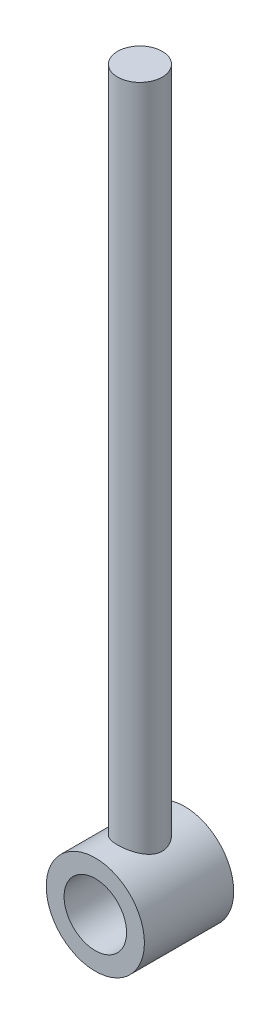
from build123d import *

# Parameters (mm, degrees)
SKETCH1_R           = 5.5
SKETCH1_R_2         = 3.5
BOSS_EXTRUDE1_DEPTH = 10
SKETCH2_R           = 2.5
BOSS_EXTRUDE2_DEPTH = 80
SKETCH3_R           = 3.5
CUT_EXTRUDE1_DEPTH  = 11.0000001


with BuildPart() as part:
    # Sketch1 → Boss-Extrude1 (new body)
    with BuildSketch(Plane.XY):
        Circle(SKETCH1_R)
        Circle(SKETCH1_R_2, mode=Mode.SUBTRACT)
    extrude(amount=BOSS_EXTRUDE1_DEPTH)

    # Sketch2 → Boss-Extrude2 (add)
    with BuildSketch(Plane(origin=(0, 0, 0), x_dir=(1, 0, 0), z_dir=(0, 1, 0))):
        with Locations((0, -5)):
            Circle(SKETCH2_R)
    extrude(amount=BOSS_EXTRUDE2_DEPTH)

    # Sketch3 → Cut-Extrude1 (cut, through all)
    with BuildSketch(Plane.XY.offset(10)):
        Circle(SKETCH3_R)
    extrude(amount=-CUT_EXTRUDE1_DEPTH, mode=Mode.SUBTRACT)


solid = part.part
